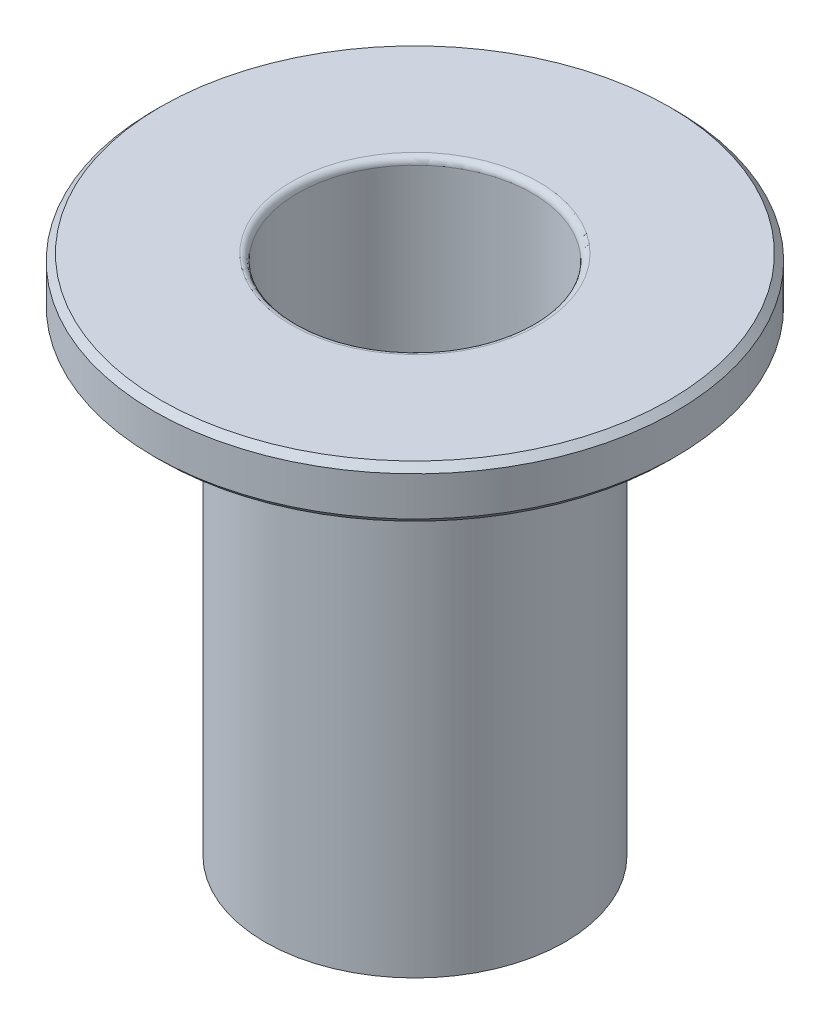
from build123d import *

# Parameters (mm, degrees)
SKETCH_1_R          = 10
EXTRUDE_1_DEPTH     = 2
SKETCH_2_R          = 5.75
EXTRUDE_2_DEPTH     = 18
CUT_EXTRUDE_1_REACH = 22
SKETCH_3_R          = 4.5
CHAMFER_1_SIZE      = 0.25
FILLET_1_R          = 0.25


with BuildPart() as part:
    # ｽｹｯﾁ1 → ﾎﾞｽ - 押し出し1 (new body)
    with BuildSketch(Plane(origin=(0, 0, 0), x_dir=(1, 0, 0), z_dir=(0, 1, 0))):
        Circle(SKETCH_1_R)
    extrude(amount=EXTRUDE_1_DEPTH)

    # ｽｹｯﾁ2 → ﾎﾞｽ - 押し出し2 (add)
    with BuildSketch(Plane.XZ):
        Circle(SKETCH_2_R)
    extrude(amount=EXTRUDE_2_DEPTH)

    # ｽｹｯﾁ3 → ｶｯﾄ - 押し出し1 (cut, up to next)
    with BuildSketch(Plane(origin=(0, 2, 0), x_dir=(1, 0, 0), z_dir=(0, 1, 0)), mode=Mode.PRIVATE) as cut_extrude_1_sk1:
        Circle(SKETCH_3_R)
    cut_extrude_1_tool1 = extrude(cut_extrude_1_sk1.sketch, amount=-CUT_EXTRUDE_1_REACH, mode=Mode.PRIVATE) & part.part
    add(cut_extrude_1_tool1.solids().sort_by_distance((0, 2, 0))[0], mode=Mode.SUBTRACT)

    # 面取り1
    chamfer_1_edges = [part.edges().sort_by_distance(p)[0] for p in [
        (-10, 0, 0),
        (-10, 2, 0),
    ]]
    chamfer(chamfer_1_edges, length=CHAMFER_1_SIZE)

    # ﾌｨﾚｯﾄ1
    fillet_1_edges = [part.edges().sort_by_distance(p)[0] for p in [
        (-4.5, -18, 0),
        (-4.5, 2, 0),
    ]]
    fillet(fillet_1_edges, radius=FILLET_1_R)


solid = part.part
